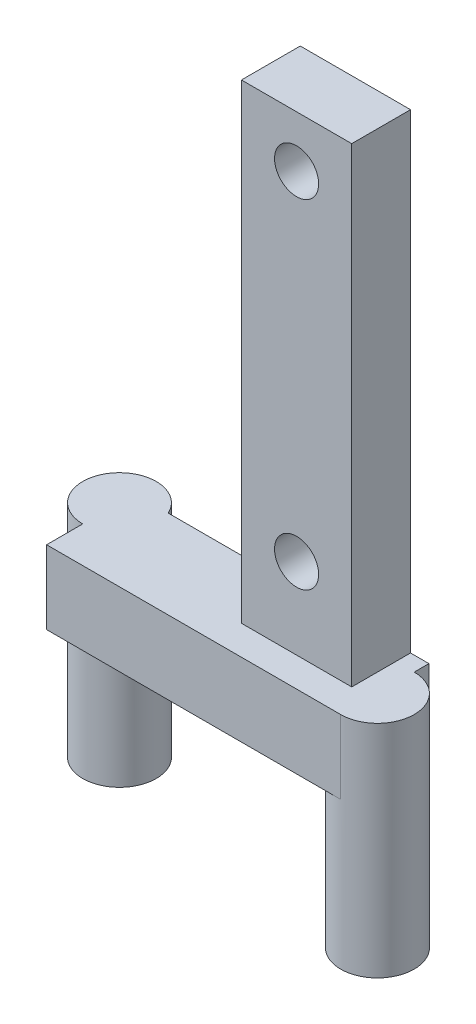
from build123d import *

# Parameters (mm, degrees)
SKETCH1_R                = 1.5
BOSS_EXTRUDE1_DEPTH      = 4
SKETCH2_W                = 10
SKETCH2_H                = 6
BOSS_EXTRUDE2_DEPTH      = 5
SKETCH7_W                = 6
SKETCH7_H                = 5
BOSS_EXTRUDE5_DEPTH      = 10
SKETCH4_R                = 2.5
BOSS_EXTRUDE3_DEPTH      = 10
BOSS_EXTRUDE3_DEPTH_BACK = 5


with BuildPart() as part:
    # Sketch1 → Boss-Extrude1 (new body)
    with BuildSketch(Plane.XY):
        Polygon((0, 0), (0, 30), (7.5, 30), (7.5, 0), (7.5, -2), (0, -2), align=None)
        with Locations((3.75, 26.5)):
            Circle(SKETCH1_R, mode=Mode.SUBTRACT)
        with Locations((3.75, 3.5)):
            Circle(SKETCH1_R, mode=Mode.SUBTRACT)
    extrude(amount=BOSS_EXTRUDE1_DEPTH)

    # Sketch2 → Boss-Extrude2 (add)
    with BuildSketch(Plane.XZ.offset(2)):
        with Locations((3.75, 3)):
            Rectangle(SKETCH2_W, SKETCH2_H)
    extrude(amount=BOSS_EXTRUDE2_DEPTH)

    # Sketch7 → Boss-Extrude5 (add)
    with BuildSketch(Plane.ZY.offset(1.25)):
        with Locations((3, -4.5)):
            Rectangle(SKETCH7_W, SKETCH7_H)
    extrude(amount=BOSS_EXTRUDE5_DEPTH)

    # Sketch4 → Boss-Extrude3 (add, two sides)
    with BuildSketch(Plane.XZ.offset(7)) as boss_extrude3_sk:
        with Locations((8.75, 3.5)):
            Circle(SKETCH4_R)
        with Locations((-11.25, 1.044308782)):
            Circle(SKETCH4_R)
    extrude(amount=BOSS_EXTRUDE3_DEPTH)
    extrude(boss_extrude3_sk.sketch, amount=-BOSS_EXTRUDE3_DEPTH_BACK)


solid = part.part
